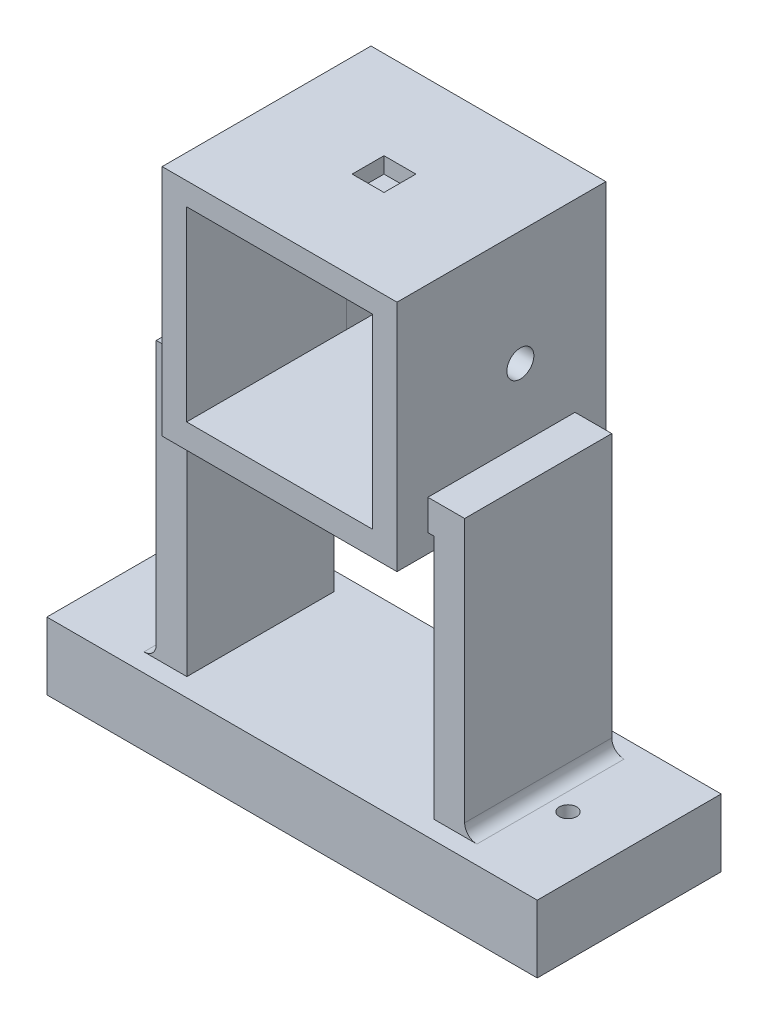
from build123d import *

# Parameters (mm, degrees)
SKETCH2_W               = 48.66
SKETCH2_H               = 48.36
BOSS_EXTRUDE1_DEPTH     = 43.2689
SKETCH3_W               = 37.992
SKETCH3_H               = 8.128
CUT_EXTRUDE1_DEPTH      = 38.1889
SKETCH4_W               = 38.5064
SKETCH4_H               = 38.608
CUT_EXTRUDE2_DEPTH      = 33.1089
SKETCH6_R               = 2.794
CUT_EXTRUDE3_DEPTH      = 78.486
CUT_EXTRUDE3_DEPTH_BACK = 23.622
SKETCH7_W               = 30.48
SKETCH7_H               = 6.35
BOSS_EXTRUDE2_DEPTH     = 7.62
SKETCH9_W               = 6.35
SKETCH9_H               = 50.8
BOSS_EXTRUDE3_DEPTH     = 30.48
SKETCH11_W              = 101.6
SKETCH11_H              = 38.1
BOSS_EXTRUDE4_DEPTH     = 13.97
SKETCH14_R              = 1.778
CUT_EXTRUDE4_DEPTH      = 13.97
FILLET1_R               = 2.54
SKETCH15_W              = 6.604
SKETCH15_H              = 6.604
CUT_EXTRUDE5_DEPTH      = 3.302


with BuildPart() as part:
    # Sketch2 → Boss-Extrude1 (new body)
    with BuildSketch(Plane.XY):
        with Locations((19.25, 19.1)):
            Rectangle(SKETCH2_W, SKETCH2_H)
    extrude(amount=BOSS_EXTRUDE1_DEPTH)

    # Sketch3 → Cut-Extrude1 (cut)
    with BuildSketch(Plane(origin=(0, 0, 0), x_dir=(-1, 0, 0), z_dir=(0, 0, -1))):
        with Locations((-18.996, 4.064)):
            Rectangle(SKETCH3_W, SKETCH3_H)
    extrude(amount=-CUT_EXTRUDE1_DEPTH, mode=Mode.SUBTRACT)

    # Sketch4 → Cut-Extrude2 (cut)
    with BuildSketch(Plane.XY.offset(43.2689)):
        with Locations((19.2468, 19.304)):
            Rectangle(SKETCH4_W, SKETCH4_H)
    extrude(amount=-CUT_EXTRUDE2_DEPTH, mode=Mode.SUBTRACT)

    # Sketch6 → Cut-Extrude3 (cut, two sides)
    with BuildSketch(Plane.ZY.offset(-38.5)) as cut_extrude3_sk:
        with Locations((17.714319607, 19.508)):
            Circle(SKETCH6_R)
    extrude(amount=CUT_EXTRUDE3_DEPTH, mode=Mode.SUBTRACT)
    extrude(cut_extrude3_sk.sketch, amount=-CUT_EXTRUDE3_DEPTH_BACK, mode=Mode.SUBTRACT)

    # Sketch7 → Boss-Extrude2 (add)
    with BuildSketch(Plane(origin=(43.58, 0, 0), x_dir=(0, 0, -1), z_dir=(1, 0, 0))):
        with Locations((-21.63445, 1.905)):
            Rectangle(SKETCH7_W, SKETCH7_H)
    boss_extrude2 = extrude(amount=BOSS_EXTRUDE2_DEPTH)

    # Sketch9 → Boss-Extrude3 (add)
    with BuildSketch(Plane.XY.offset(36.87445)):
        with Locations((48.025, -26.67)):
            Rectangle(SKETCH9_W, SKETCH9_H)
    boss_extrude3 = extrude(amount=-BOSS_EXTRUDE3_DEPTH)

    # Mirror1: Boss-Extrude2, Boss-Extrude3 across plane
    add(boss_extrude2.mirror(Plane(origin=(19.25, 0, 0), x_dir=(0, 0, 1), z_dir=(1, 0, 0))))
    add(boss_extrude3.mirror(Plane(origin=(19.25, 0, 0), x_dir=(0, 0, 1), z_dir=(1, 0, 0))))

    # Sketch11 → Boss-Extrude4 (add)
    with BuildSketch(Plane.XZ.offset(52.07)):
        with Locations((19.25, 21.63445)):
            Rectangle(SKETCH11_W, SKETCH11_H)
    extrude(amount=BOSS_EXTRUDE4_DEPTH)

    # Sketch14 → Cut-Extrude4 (cut)
    with BuildSketch(Plane.XZ.offset(66.04)):
        with Locations((57.376985722, 21.63445)):
            Circle(SKETCH14_R)
        with Locations((-18.876985722, 21.63445)):
            Circle(SKETCH14_R)
    extrude(amount=-CUT_EXTRUDE4_DEPTH, mode=Mode.SUBTRACT)

    # Fillet1
    fillet1_edges = [part.edges().sort_by_distance(p)[0] for p in [
        (-12.7, -52.07, 21.63445),
        (51.2, -52.07, 21.63445),
    ]]
    fillet(fillet1_edges, radius=FILLET1_R)

    # Sketch15 → Cut-Extrude5 (cut)
    with BuildSketch(Plane(origin=(0, 43.28, 0), x_dir=(1, 0, 0), z_dir=(0, 1, 0))):
        with Locations((19.25, -21.63445)):
            Rectangle(SKETCH15_W, SKETCH15_H)
    extrude(amount=-CUT_EXTRUDE5_DEPTH, mode=Mode.SUBTRACT)


solid = part.part
